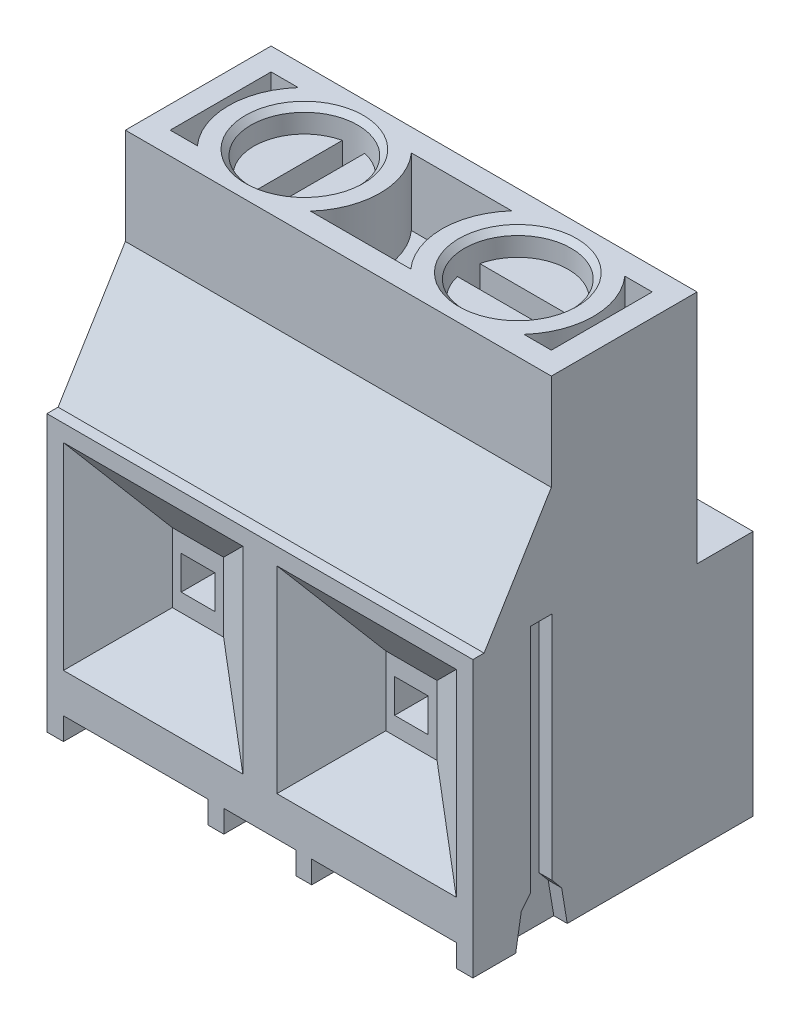
from build123d import *

# Parameters (mm, degrees)
BOSS_EXTRUDE1_DEPTH   = 19
SKETCH2_R             = 2.38
CUT_EXTRUDE1_DEPTH    = 3
CUT_EXTRUDE2_DEPTH    = 0.6
SKETCH4_W             = 0.96
SKETCH4_H             = 12.3
BOSS_EXTRUDE2_DEPTH   = 0.6
CHAMFER1_SIZE         = 0.25
SKETCH6_R             = 2.25
BOSS_EXTRUDE3_DEPTH   = 2
BOSS_EXTRUDE3_2_DEPTH = 2
CUT_EXTRUDE3_DEPTH    = 1
SKETCH8_W             = 8
SKETCH8_H             = 8.8
CUT_EXTRUDE4_DEPTH    = 2
CUT_EXTRUDE4_TAPER    = 55
SKETCH9_W             = 1.5
SKETCH9_H             = 1.5
CUT_EXTRUDE5_DEPTH    = 2
SKETCH10_W            = 6.45
SKETCH10_H            = 1
SKETCH10_W_2          = 3.22
CUT_EXTRUDE6_DEPTH    = 13.5


with BuildPart() as part:
    # Sketch1 → Boss-Extrude1 (new body)
    with BuildSketch(Plane(origin=(0, 0, 0), x_dir=(0, 0, -1), z_dir=(1, 0, 0))):
        Polygon((0, 0), (0, 12.3), (0.5, 12.3), (3.5, 17.2), (3.5, 21.5), (10, 21.5), (10, 11), (12.5, 11), (12.5, 0), align=None)
    extrude(amount=BOSS_EXTRUDE1_DEPTH)

    # Sketch2 → Cut-Extrude1 (cut)
    with BuildSketch(Plane(origin=(0, 21.5, 0), x_dir=(1, 0, 0), z_dir=(0, 1, 0))):
        with Locations((4.735, 6.75)):
            Circle(SKETCH2_R)
        with Locations((14.255, 6.75)):
            Circle(SKETCH2_R)
        with BuildLine():
            Line((16.777280714, 4.5), (18, 4.5))
            Line((18, 4.5), (18, 9))
            Line((18, 9), (16.777280714, 9))
            ThreePointArc((16.777280714, 9), (17.635, 6.75), (16.777280714, 4.5))
        make_face()
        with BuildLine():
            Line((11.732719286, 9), (7.257280714, 9))
            ThreePointArc((7.257280714, 9), (8.115, 6.75), (7.257280714, 4.5))
            Line((7.257280714, 4.5), (11.732719286, 4.5))
            ThreePointArc((11.732719286, 4.5), (10.875, 6.75), (11.732719286, 9))
        make_face()
        with BuildLine():
            Line((1, 9), (1, 4.5))
            Line((1, 4.5), (2.212719286, 4.5))
            ThreePointArc((2.212719286, 4.5), (1.355, 6.75), (2.212719286, 9))
            Line((2.212719286, 9), (1, 9))
        make_face()
    extrude(amount=-CUT_EXTRUDE1_DEPTH, mode=Mode.SUBTRACT)

    # Sketch3 → Cut-Extrude2 (cut)
    with BuildSketch(Plane(origin=(19, 0, 0), x_dir=(0, 0, -1), z_dir=(1, 0, 0))):
        Polygon((1.91, 0), (2.16, 1.5), (2.58, 2), (2.58, 12.3), (3.54, 12.3), (3.54, 2), (3.96, 1.5), (4.21, 0), align=None)
    extrude(amount=-CUT_EXTRUDE2_DEPTH, mode=Mode.SUBTRACT)

    # Sketch4 → Boss-Extrude2 (add)
    with BuildSketch(Plane.ZY):
        with Locations((-3.06, 6.15)):
            Rectangle(SKETCH4_W, SKETCH4_H)
    extrude(amount=BOSS_EXTRUDE2_DEPTH)

    # Chamfer1
    chamfer1_edges = [part.edges().sort_by_distance(p)[0] for p in [
        (2.355, 21.5, -6.75),
        (11.875, 21.5, -6.75),
    ]]
    chamfer(chamfer1_edges, length=CHAMFER1_SIZE)

    # Sketch8 → Cut-Extrude4 (cut)
    with BuildSketch(Plane.XY):
        with Locations((14.26, 7.15)):
            Rectangle(SKETCH8_W, SKETCH8_H)
        with Locations((4.74, 7.15)):
            Rectangle(SKETCH8_W, SKETCH8_H)
    extrude(amount=-CUT_EXTRUDE4_DEPTH, taper=CUT_EXTRUDE4_TAPER, mode=Mode.SUBTRACT)

    # Sketch9 → Cut-Extrude5 (cut)
    with BuildSketch(Plane.XY.offset(-2)):
        with Locations((4.74, 7.15)):
            Rectangle(SKETCH9_W, SKETCH9_H)
        with Locations((14.26, 7.15)):
            Rectangle(SKETCH9_W, SKETCH9_H)
    extrude(amount=-CUT_EXTRUDE5_DEPTH, mode=Mode.SUBTRACT)

    # Sketch10 → Cut-Extrude6 (cut, through all)
    with BuildSketch(Plane.XY):
        with Locations((3.965, 0.5)):
            Rectangle(SKETCH10_W, SKETCH10_H)
        with Locations((9.5, 0.5)):
            Rectangle(SKETCH10_W_2, SKETCH10_H)
        with Locations((15.035, 0.5)):
            Rectangle(SKETCH10_W, SKETCH10_H)
    extrude(amount=-CUT_EXTRUDE6_DEPTH, mode=Mode.SUBTRACT)


with BuildPart() as body_2:
    # Sketch6 → Boss-Extrude3 (new body)
    with BuildSketch(Plane(origin=(0, 18.5, 0), x_dir=(1, 0, 0), z_dir=(0, 1, 0))):
        with Locations((14.255, 6.75)):
            Circle(SKETCH6_R)
    extrude(amount=BOSS_EXTRUDE3_DEPTH)


with BuildPart() as body_3:
    # Sketch6 → Boss-Extrude3 2 (new body)
    with BuildSketch(Plane(origin=(0, 18.5, 0), x_dir=(1, 0, 0), z_dir=(0, 1, 0))):
        with Locations((4.735, 6.75)):
            Circle(SKETCH6_R)
    extrude(amount=BOSS_EXTRUDE3_2_DEPTH)


with BuildPart() as cut_extrude3_tool:
    # Sketch7 → Cut-Extrude3 (new body)
    with BuildSketch(Plane(origin=(0, 20.5, 0), x_dir=(1, 0, 0), z_dir=(0, 1, 0))):
        with BuildLine():
            Line((4.235, 8.943741097), (4.235, 4.556258903))
            ThreePointArc((4.235, 4.556258903), (4.735, 4.5), (5.235, 4.556258903))
            Line((5.235, 4.556258903), (5.235, 8.943741097))
            ThreePointArc((5.235, 8.943741097), (4.735, 9), (4.235, 8.943741097))
        make_face()
        with BuildLine():
            Line((12.061258903, 7.25), (16.448741097, 7.25))
            ThreePointArc((16.448741097, 7.25), (16.505, 6.75), (16.448741097, 6.25))
            Line((16.448741097, 6.25), (12.061258903, 6.25))
            ThreePointArc((12.061258903, 6.25), (12.005, 6.75), (12.061258903, 7.25))
        make_face()
    extrude(amount=-CUT_EXTRUDE3_DEPTH)


with BuildPart() as body_2_1:
    add(body_2.part)

    # Cut-Extrude3: cut by cut_extrude3_tool
    add(cut_extrude3_tool.part, mode=Mode.SUBTRACT)


with BuildPart() as body_3_1:
    add(body_3.part)

    # Cut-Extrude3: cut by cut_extrude3_tool
    add(cut_extrude3_tool.part, mode=Mode.SUBTRACT)


solid = Compound([part.part, body_2_1.part, body_3_1.part])
